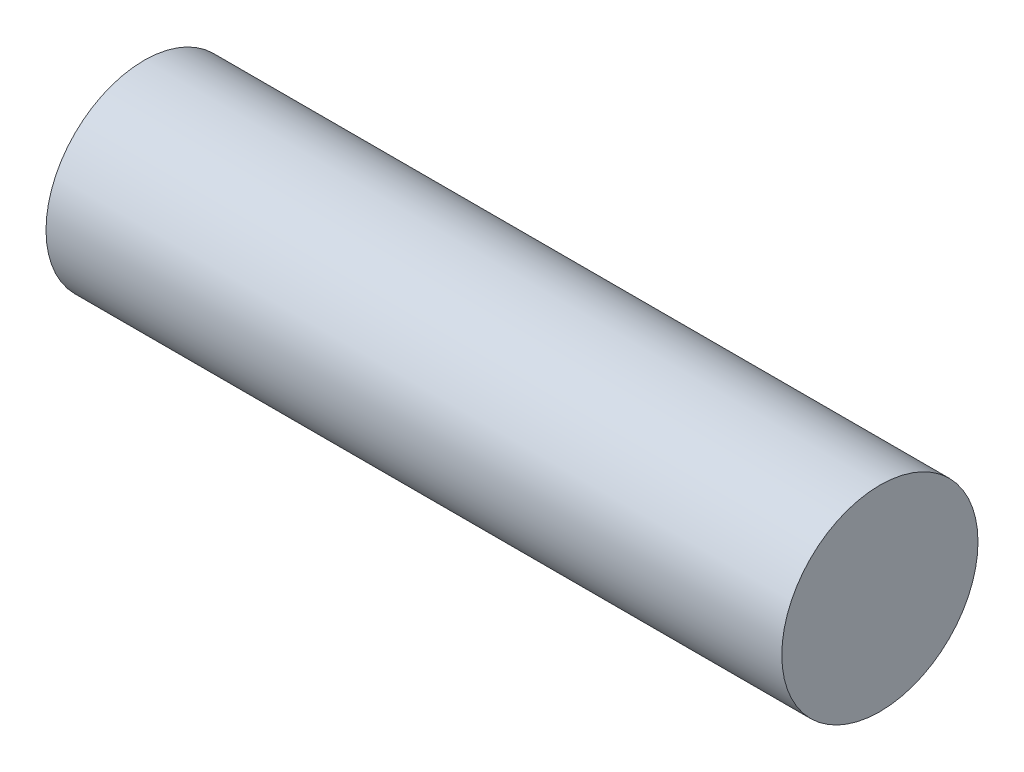
from build123d import *

# Parameters (mm, degrees)
RIVETPROFILE_R      = 40
BOSS_EXTRUDE1_DEPTH = 300


with BuildPart() as part:
    # RivetProfile → Boss-Extrude1 (new body)
    with BuildSketch(Plane(origin=(0, 0, 0), x_dir=(0, 0, -1), z_dir=(1, 0, 0))):
        Circle(RIVETPROFILE_R)
    extrude(amount=BOSS_EXTRUDE1_DEPTH)


solid = part.part
